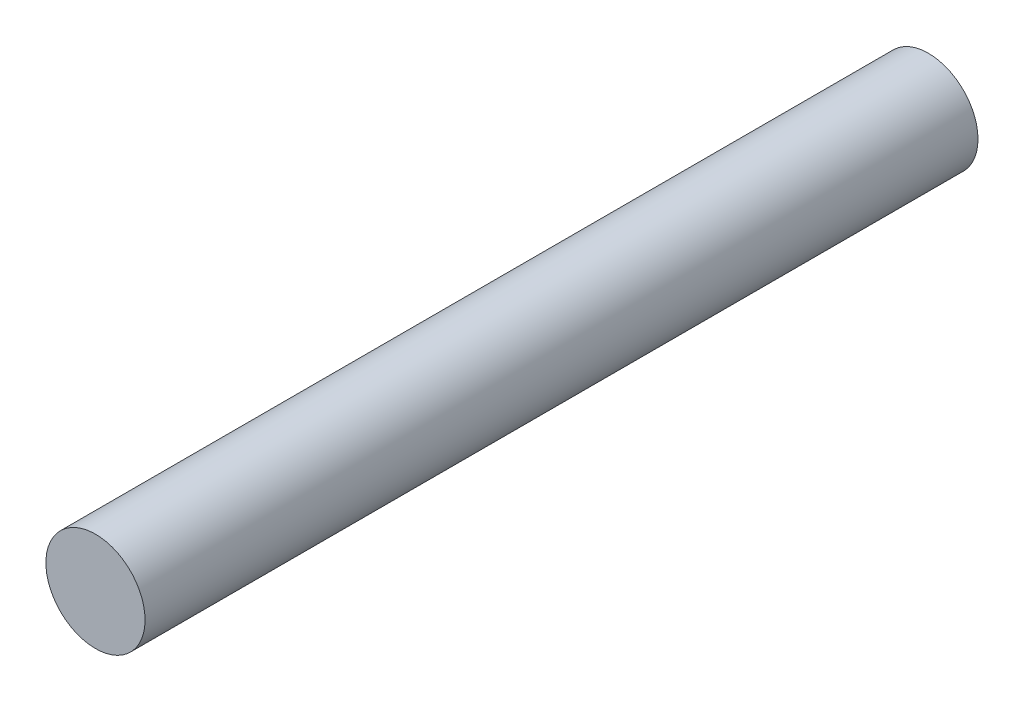
from build123d import *

# Parameters (mm, degrees)
ESQUISSE1_R        = 2.5
BOSS_EXTRU_3_DEPTH = 42


with BuildPart() as part:
    # Esquisse1 → Boss.-Extru.3 (new body)
    with BuildSketch(Plane.XY):
        with Locations((-8.76672707, 13.058770531)):
            Circle(ESQUISSE1_R)
    extrude(amount=BOSS_EXTRU_3_DEPTH)


solid = part.part
